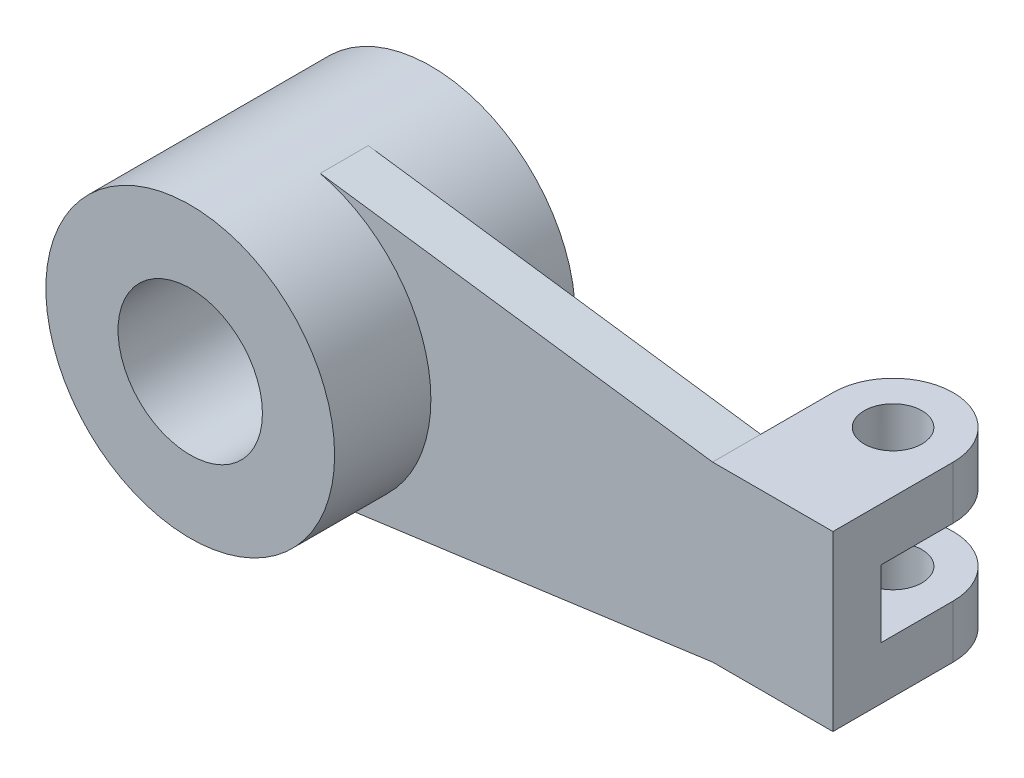
from build123d import *

# Parameters (mm, degrees)
SKETCH2_R           = 30
SKETCH2_R_2         = 15
BOSS_EXTRUDE1_DEPTH = 25
BOSS_EXTRUDE2_DEPTH = 5
SKETCH4_R           = 6
BOSS_EXTRUDE3_DEPTH = 36
SKETCH5_W           = 15
SKETCH5_H           = 7
CUT_EXTRUDE1_DEPTH  = 36


with BuildPart() as part:
    # Sketch2 → Boss-Extrude1 (new body, symmetric)
    with BuildSketch(Plane.XY):
        Circle(SKETCH2_R)
        Circle(SKETCH2_R_2, mode=Mode.SUBTRACT)
    extrude(amount=BOSS_EXTRUDE1_DEPTH, both=True)

    # Sketch3 → Boss-Extrude2 (add, symmetric)
    with BuildSketch(Plane.XY):
        with BuildLine():
            Line((113.533737607, 0), (113.533737607, 18))
            Line((113.533737607, 18), (88.533737607, 18))
            Line((88.533737607, 18), (6.995589774, 29.172962203))
            ThreePointArc((6.995589774, 29.172962203), (29.999485022, 0.175779521), (7.336970855, -29.08898174))
            Line((7.336970855, -29.08898174), (88.533737607, -18))
            Line((88.533737607, -18), (113.533737607, -18))
            Line((113.533737607, -18), (113.533737607, 0))
        make_face()
    extrude(amount=BOSS_EXTRUDE2_DEPTH, both=True)

    # Sketch4 → Boss-Extrude3 (add)
    with BuildSketch(Plane(origin=(0, 18, 0), x_dir=(1, 0, 0), z_dir=(0, 1, 0))):
        with BuildLine():
            Line((88.533737607, 20), (88.533737607, 5))
            Line((88.533737607, 5), (113.533737607, 5))
            Line((113.533737607, 5), (113.533737607, 20))
            ThreePointArc((113.533737607, 20), (101.033737607, 32.5), (88.533737607, 20))
        make_face()
        with Locations(Location((101.033737607, 20, 0), (0, 0, 180))):  # turned: the seam where the file's is
            Circle(SKETCH4_R, mode=Mode.SUBTRACT)
    extrude(amount=-BOSS_EXTRUDE3_DEPTH)

    # Sketch5 → Cut-Extrude1 (cut)
    with BuildSketch(Plane(origin=(113.533737607, 0, 0), x_dir=(0, 0, -1), z_dir=(1, 0, 0))):
        with Locations((12.5, -3.5)):
            Rectangle(SKETCH5_W, SKETCH5_H)
        with Locations((12.5, 3.5)):
            Rectangle(SKETCH5_W, SKETCH5_H)
        Polygon((20, 7), (20, 0), (31.178860048, 0), (40, 0), (40, 7), align=None)
        Polygon((31.178860048, 0), (20, 0), (20, -7), (40, -7), (40, 0), align=None)
    extrude(amount=-CUT_EXTRUDE1_DEPTH, mode=Mode.SUBTRACT)


solid = part.part
